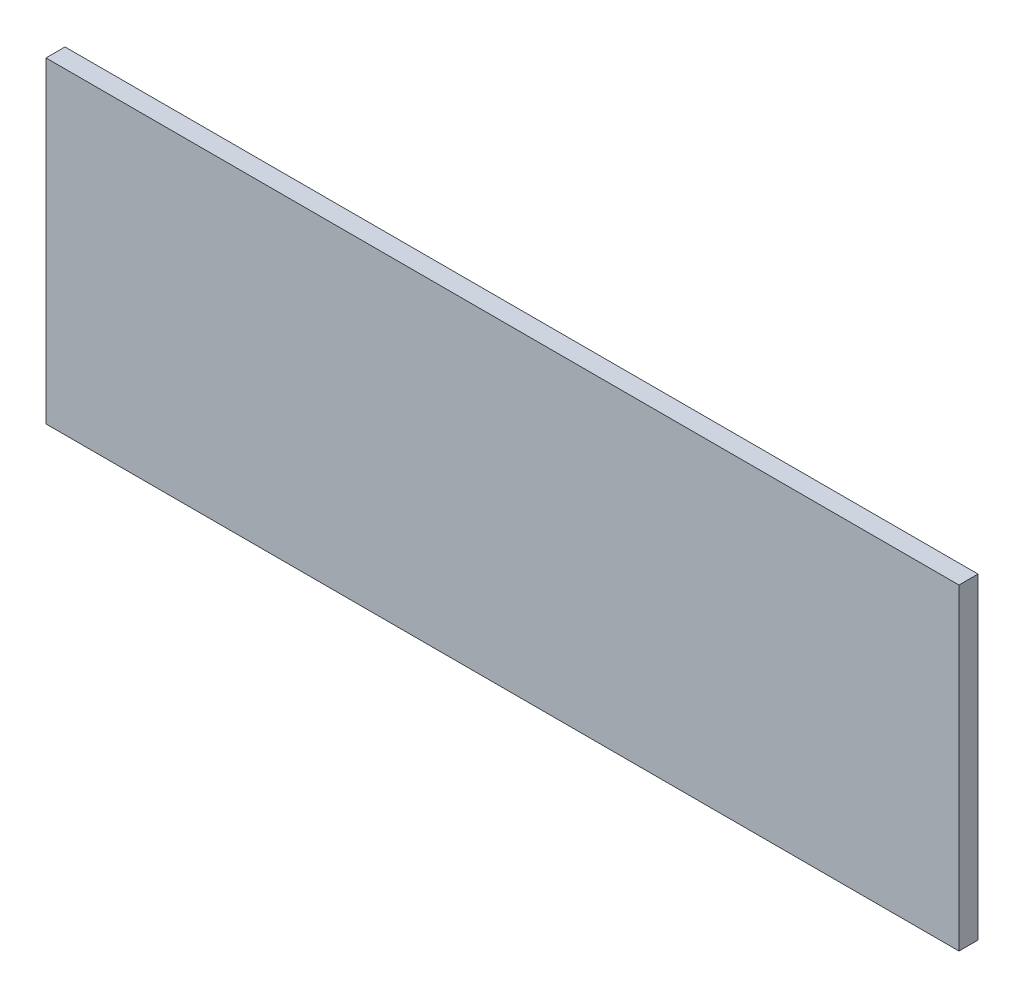
from build123d import *

# Parameters (mm, degrees)
SKETCH1_W           = 144
SKETCH1_H           = 50
BOSS_EXTRUDE1_DEPTH = 3


with BuildPart() as part:
    # Sketch1 → Boss-Extrude1 (new body)
    with BuildSketch(Plane.XY):
        Rectangle(SKETCH1_W, SKETCH1_H)
    extrude(amount=BOSS_EXTRUDE1_DEPTH)


solid = part.part
